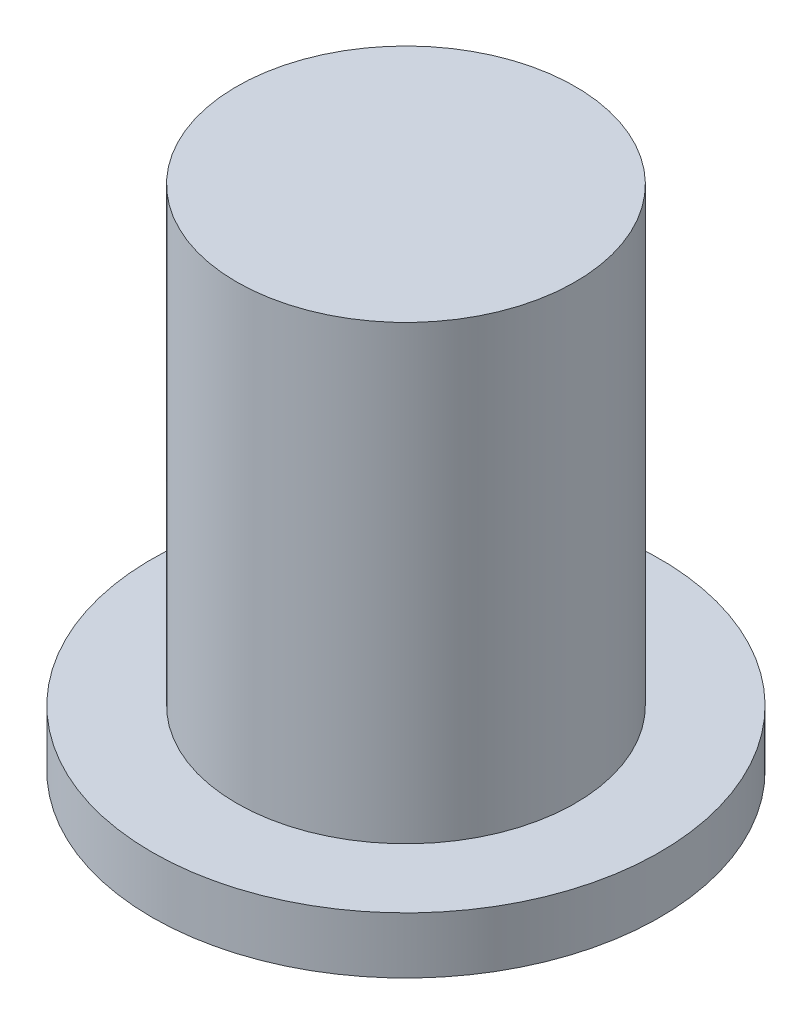
from build123d import *

# Parameters (mm, degrees)
SKETCH1_R           = 4.5
BOSS_EXTRUDE1_DEPTH = 1
SKETCH2_R           = 3
BOSS_EXTRUDE2_DEPTH = 8


with BuildPart() as part:
    # Sketch1 → Boss-Extrude1 (new body)
    with BuildSketch(Plane(origin=(0, 0, 0), x_dir=(1, 0, 0), z_dir=(0, 1, 0))):
        Circle(SKETCH1_R)
    extrude(amount=BOSS_EXTRUDE1_DEPTH)

    # Sketch2 → Boss-Extrude2 (add)
    with BuildSketch(Plane(origin=(0, 1, 0), x_dir=(1, 0, 0), z_dir=(0, 1, 0))):
        Circle(SKETCH2_R)
    extrude(amount=BOSS_EXTRUDE2_DEPTH)


solid = part.part
